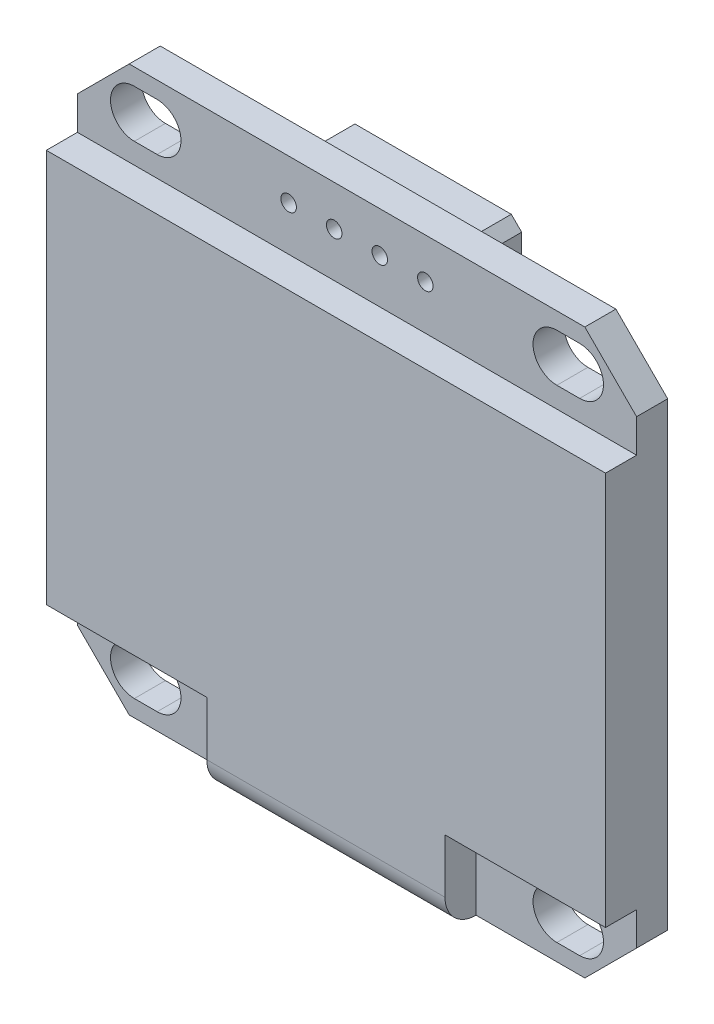
from build123d import *

# Parameters (mm, degrees)
ESQUISSE1_R        = 0.375
BOSS_EXTRU_1_DEPTH = 1.5
BOSS_EXTRU_2_DEPTH = 1.5
CONG_1_R           = 1.5
ESQUISSE3_R        = 0.375
BOSS_EXTRU_3_DEPTH = 2.3


with BuildPart() as part:
    # Esquisse1 → Boss.-Extru.1 (new body)
    with BuildSketch(Plane.XY):
        Polygon((0, -1.46), (2.5, -3.96), (24.5, -3.96), (27, -1.46), (27, 20.76), (24.5, 23.26), (2.5, 23.26), (0, 20.76), align=None)
        with Locations((10.2, 21.3)):
            Circle(ESQUISSE1_R, mode=Mode.SUBTRACT)
        with Locations((12.4, 21.3)):
            Circle(ESQUISSE1_R, mode=Mode.SUBTRACT)
        with Locations((14.6, 21.3)):
            Circle(ESQUISSE1_R, mode=Mode.SUBTRACT)
        with Locations((16.8, 21.3)):
            Circle(ESQUISSE1_R, mode=Mode.SUBTRACT)
        with BuildLine():
            Line((2.75, 22.45), (3.85, 22.45))
            ThreePointArc((3.85, 22.45), (5, 21.3), (3.85, 20.15))
            Line((3.85, 20.15), (2.75, 20.15))
            ThreePointArc((2.75, 20.15), (1.6, 21.3), (2.75, 22.45))
        make_face(mode=Mode.SUBTRACT)
        with BuildLine():
            Line((24.25, 22.45), (23.15, 22.45))
            ThreePointArc((23.15, 22.45), (22, 21.3), (23.15, 20.15))
            Line((23.15, 20.15), (24.25, 20.15))
            ThreePointArc((24.25, 20.15), (25.4, 21.3), (24.25, 22.45))
        make_face(mode=Mode.SUBTRACT)
        with BuildLine():
            Line((24.25, -3.15), (23.15, -3.15))
            ThreePointArc((23.15, -3.15), (22, -2), (23.15, -0.85))
            Line((23.15, -0.85), (24.25, -0.85))
            ThreePointArc((24.25, -0.85), (25.4, -2), (24.25, -3.15))
        make_face(mode=Mode.SUBTRACT)
        with BuildLine():
            Line((2.75, -3.15), (3.85, -3.15))
            ThreePointArc((3.85, -3.15), (5, -2), (3.85, -0.85))
            Line((3.85, -0.85), (2.75, -0.85))
            ThreePointArc((2.75, -0.85), (1.6, -2), (2.75, -3.15))
        make_face(mode=Mode.SUBTRACT)
    extrude(amount=BOSS_EXTRU_1_DEPTH)

    # Esquisse2 → Boss.-Extru.2 (add)
    with BuildSketch(Plane.XY.offset(1.5)):
        Polygon((0, 19.15), (27, 19.15), (27, 0.15), (19.25, 0.15), (19.25, -3.96), (7.75, -3.96), (7.75, 0.15), (0, 0.15), align=None)
    extrude(amount=BOSS_EXTRU_2_DEPTH)

    # Congé1
    cong_1_edges = [part.edges().sort_by_distance(p)[0] for p in [
        (13.5, -3.96, 3),
    ]]
    fillet(cong_1_edges, radius=CONG_1_R)

    # Esquisse3 → Boss.-Extru.3 (add)
    with BuildSketch(Plane(origin=(0, 0, 0), x_dir=(-1, 0, 0), z_dir=(0, 0, -1))):
        Polygon((-17.65, 20.7), (-17.15, 20.2), (-15.45, 20.2), (-13.5, 20.2), (-11.3, 20.2), (-9.6, 20.2), (-9.1, 20.7), (-9.1, 21.9), (-9.6, 22.4), (-11.3, 22.4), (-13.5, 22.4), (-15.45, 22.4), (-17.15, 22.4), (-17.65, 21.9), align=None)
        with Locations((-10.2, 21.3)):
            Circle(ESQUISSE3_R, mode=Mode.SUBTRACT)
        with Locations((-16.8, 21.3)):
            Circle(ESQUISSE3_R, mode=Mode.SUBTRACT)
        with Locations((-12.4, 21.3)):
            Circle(ESQUISSE3_R, mode=Mode.SUBTRACT)
        with Locations((-14.6, 21.3)):
            Circle(ESQUISSE3_R, mode=Mode.SUBTRACT)
    extrude(amount=BOSS_EXTRU_3_DEPTH)


solid = part.part
